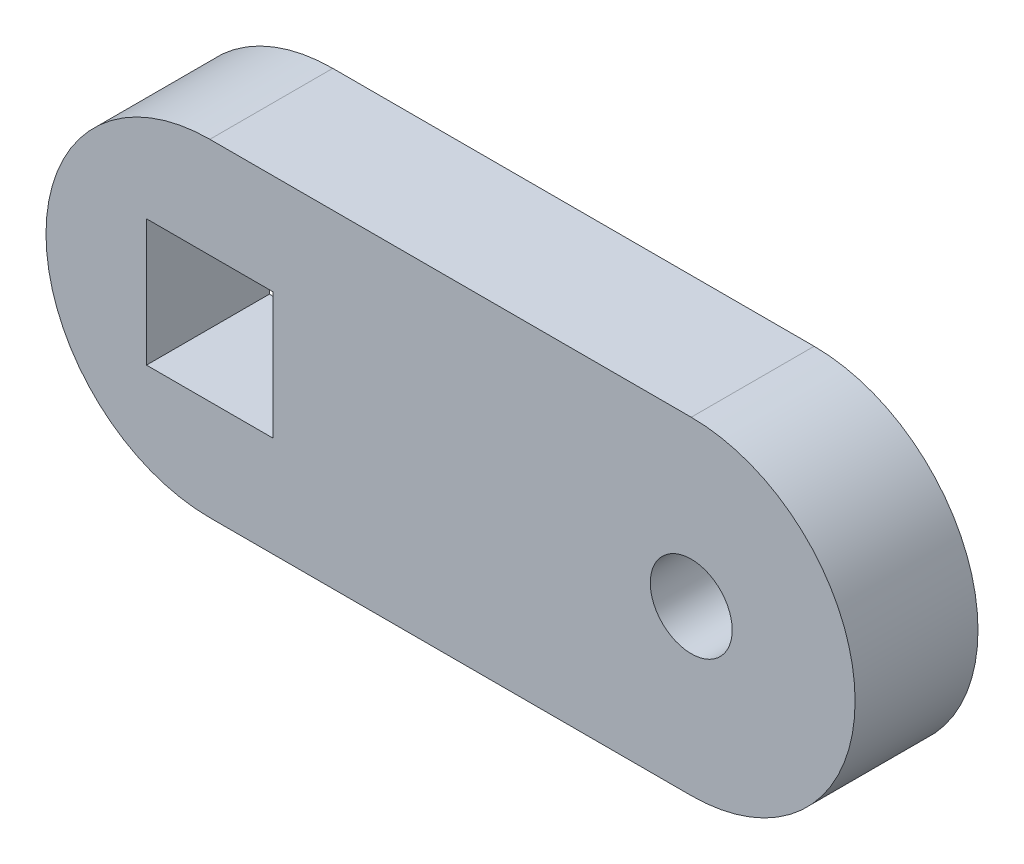
from build123d import *

# Parameters (mm, degrees)
MODEL_R             = 2
BOSS_EXTRUDE1_DEPTH = 6


with BuildPart() as part:
    # Model → Boss-Extrude1 (new body)
    with BuildSketch(Plane.XY):
        with BuildLine():
            Line((26.526195336, 21.768592837), (50.026195336, 21.768592837))
            ThreePointArc((50.026195336, 21.768592837), (58.026195336, 13.768592837), (50.026195336, 5.768592837))
            Line((50.026195336, 5.768592837), (26.526195336, 5.768592837))
            ThreePointArc((26.526195336, 5.768592837), (18.526195336, 13.768592837), (26.526195336, 21.768592837))
        make_face()
        with Locations((50.026195336, 13.768592837)):
            Circle(MODEL_R, mode=Mode.SUBTRACT)
        Polygon((29.619945336, 13.768592837), (29.619945336, 16.862342837), (23.432445336, 16.862342837), (23.432445336, 10.674842837), (29.619945336, 10.674842837), align=None, mode=Mode.SUBTRACT)
    extrude(amount=BOSS_EXTRUDE1_DEPTH)


solid = part.part
